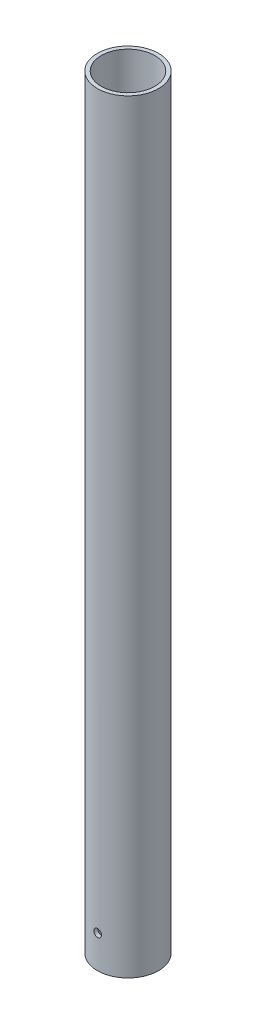
from build123d import *

# Parameters (mm, degrees)
SKETCH1_R               = 8
SKETCH1_R_2             = 7
BOSS_EXTRUDE1_DEPTH     = 200
SKETCH2_R               = 1
CUT_EXTRUDE1_DEPTH      = 9
CUT_EXTRUDE1_DEPTH_BACK = 9


with BuildPart() as part:
    # Sketch1 → Boss-Extrude1 (new body)
    with BuildSketch(Plane(origin=(0, 0, 0), x_dir=(1, 0, 0), z_dir=(0, 1, 0))):
        Circle(SKETCH1_R)
        Circle(SKETCH1_R_2, mode=Mode.SUBTRACT)
    extrude(amount=BOSS_EXTRUDE1_DEPTH)

    # Sketch2 → Cut-Extrude1 (cut, two sides)
    with BuildSketch(Plane.XY) as cut_extrude1_sk:
        with Locations((0, 8.56358164)):
            Circle(SKETCH2_R)
    extrude(amount=CUT_EXTRUDE1_DEPTH, mode=Mode.SUBTRACT)
    extrude(cut_extrude1_sk.sketch, amount=-CUT_EXTRUDE1_DEPTH_BACK, mode=Mode.SUBTRACT)


solid = part.part
